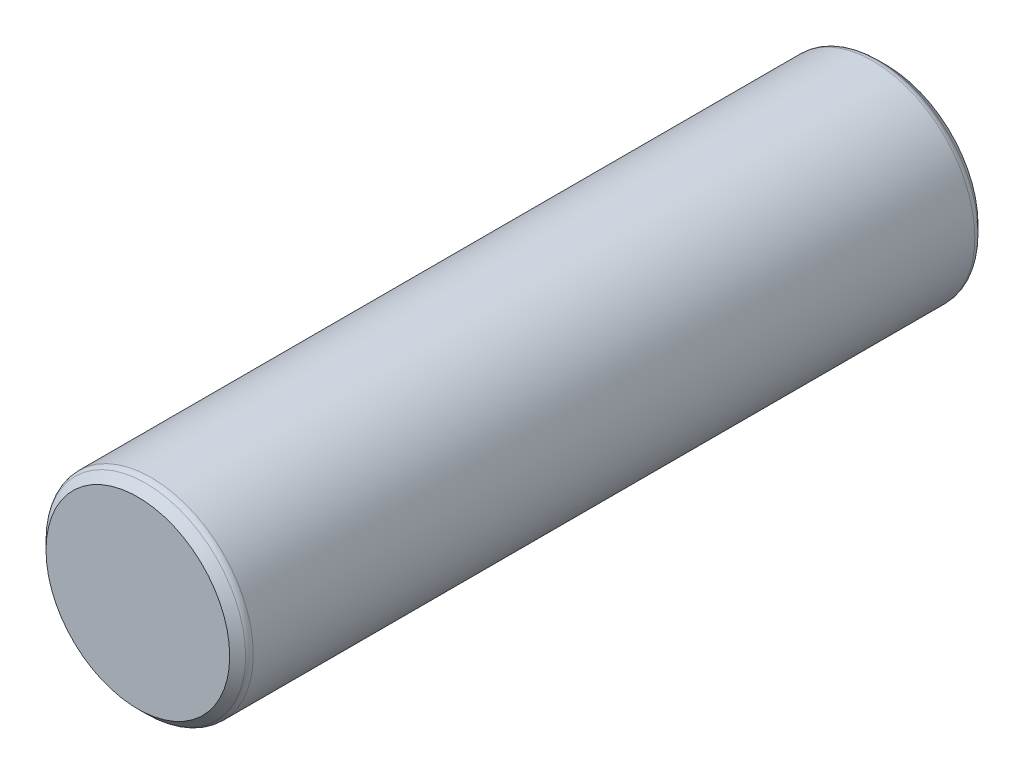
from build123d import *

# Parameters (mm, degrees)
SKETCH3_R           = 7.5
BOSS_EXTRUDE1_DEPTH = 27.5
CHAMFER1_SIZE       = 0.75
FILLET2_R           = 0.5625


with BuildPart() as part:
    # Sketch3 → Boss-Extrude1 (new, symmetric)
    with BuildSketch(Plane.XY):
        Circle(SKETCH3_R)
    extrude(amount=BOSS_EXTRUDE1_DEPTH, both=True)

    # Chamfer1
    chamfer1_edges = [part.edges().sort_by_distance(p)[0] for p in [
        (-7.5, 0, -27.5),
        (-7.5, 0, 27.5),
    ]]
    chamfer(chamfer1_edges, length=CHAMFER1_SIZE)

    # Fillet2
    fillet2_edges = [part.edges().sort_by_distance(p)[0] for p in [
        (-7.5, 0, -26.75),
        (-7.5, 0, 26.75),
    ]]
    fillet(fillet2_edges, radius=FILLET2_R)


solid = part.part
